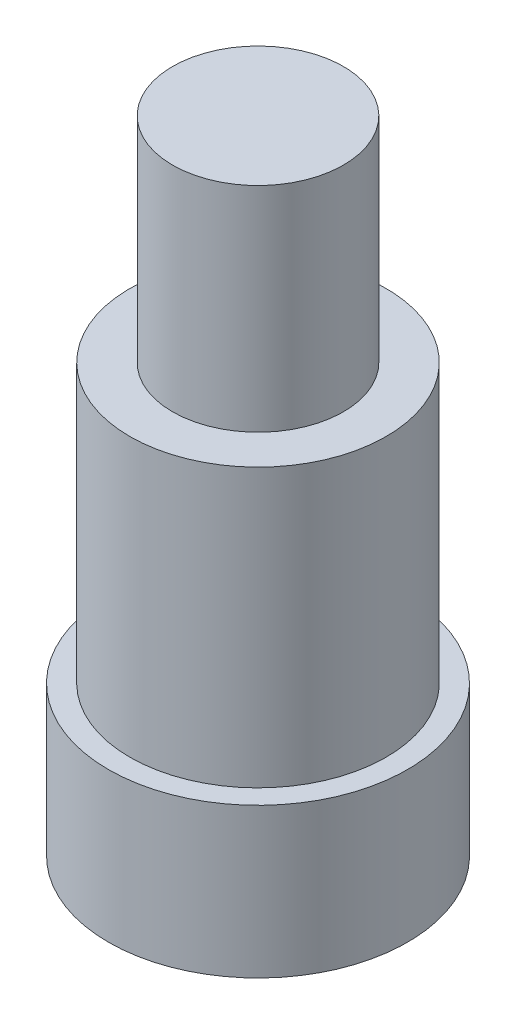
from build123d import *

# Parameters (mm, degrees)
SKETCH1_R           = 7
BOSS_EXTRUDE1_DEPTH = 7
SKETCH2_R           = 6
BOSS_EXTRUDE2_DEPTH = 13
SKETCH3_R           = 4
BOSS_EXTRUDE3_DEPTH = 10


with BuildPart() as part:
    # Sketch1 → Boss-Extrude1 (new body)
    with BuildSketch(Plane(origin=(0, 0, 0), x_dir=(1, 0, 0), z_dir=(0, 1, 0))):
        Circle(SKETCH1_R)
    extrude(amount=BOSS_EXTRUDE1_DEPTH)

    # Sketch2 → Boss-Extrude2 (add)
    with BuildSketch(Plane(origin=(0, 7, 0), x_dir=(1, 0, 0), z_dir=(0, 1, 0))):
        Circle(SKETCH2_R)
    extrude(amount=BOSS_EXTRUDE2_DEPTH)

    # Sketch3 → Boss-Extrude3 (add)
    with BuildSketch(Plane(origin=(0, 20, 0), x_dir=(1, 0, 0), z_dir=(0, 1, 0))):
        Circle(SKETCH3_R)
    extrude(amount=BOSS_EXTRUDE3_DEPTH)


solid = part.part
